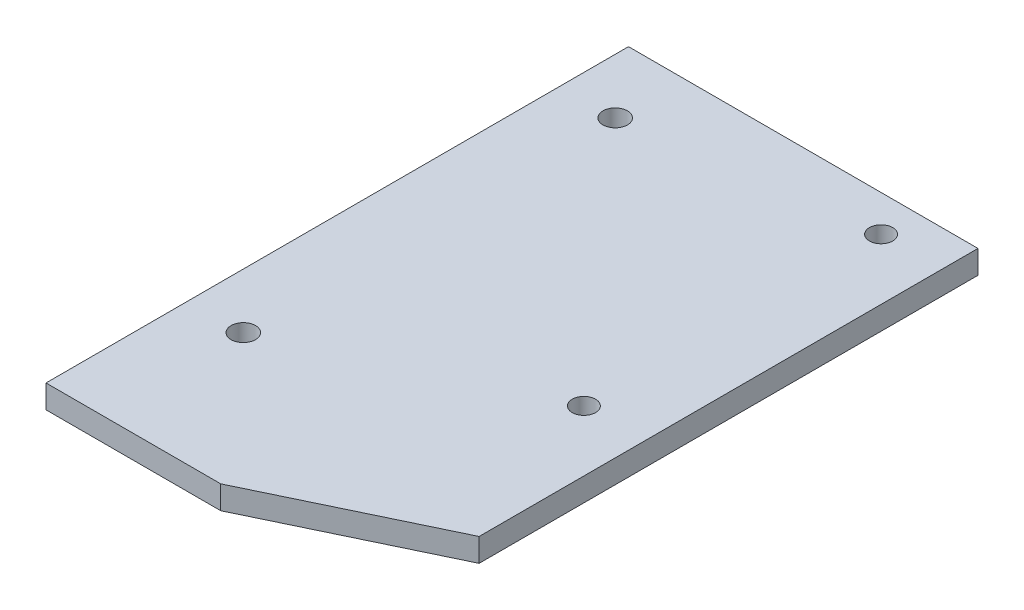
from build123d import *

# Parameters (mm, degrees)
BOSS_EXTRUDE1_DEPTH = 2
SKETCH2_R           = 1.05
SKETCH2_R_2         = 1
CUT_EXTRUDE1_DEPTH  = 2


with BuildPart() as part:
    # Sketch1 → Boss-Extrude1 (new body)
    with BuildSketch(Plane(origin=(0, 0, 0), x_dir=(1, 0, 0), z_dir=(0, 1, 0))):
        Polygon((15, 0), (30, 7.176715965), (30, 50), (0, 50), (0, 0), align=None)
    extrude(amount=BOSS_EXTRUDE1_DEPTH)

    # Sketch2 → Cut-Extrude1 (cut)
    with BuildSketch(Plane(origin=(0, 2, 0), x_dir=(1, 0, 0), z_dir=(0, 1, 0))):
        with Locations((4.726617713, 12.209983797)):
            Circle(SKETCH2_R)
        with Locations((4.726617713, 44.133312649)):
            Circle(SKETCH2_R)
        with Locations((24.790740166, 46.891267625)):
            Circle(SKETCH2_R_2)
        with Locations((24.790740166, 21.380184093)):
            Circle(SKETCH2_R_2)
    extrude(amount=-CUT_EXTRUDE1_DEPTH, mode=Mode.SUBTRACT)


solid = part.part
